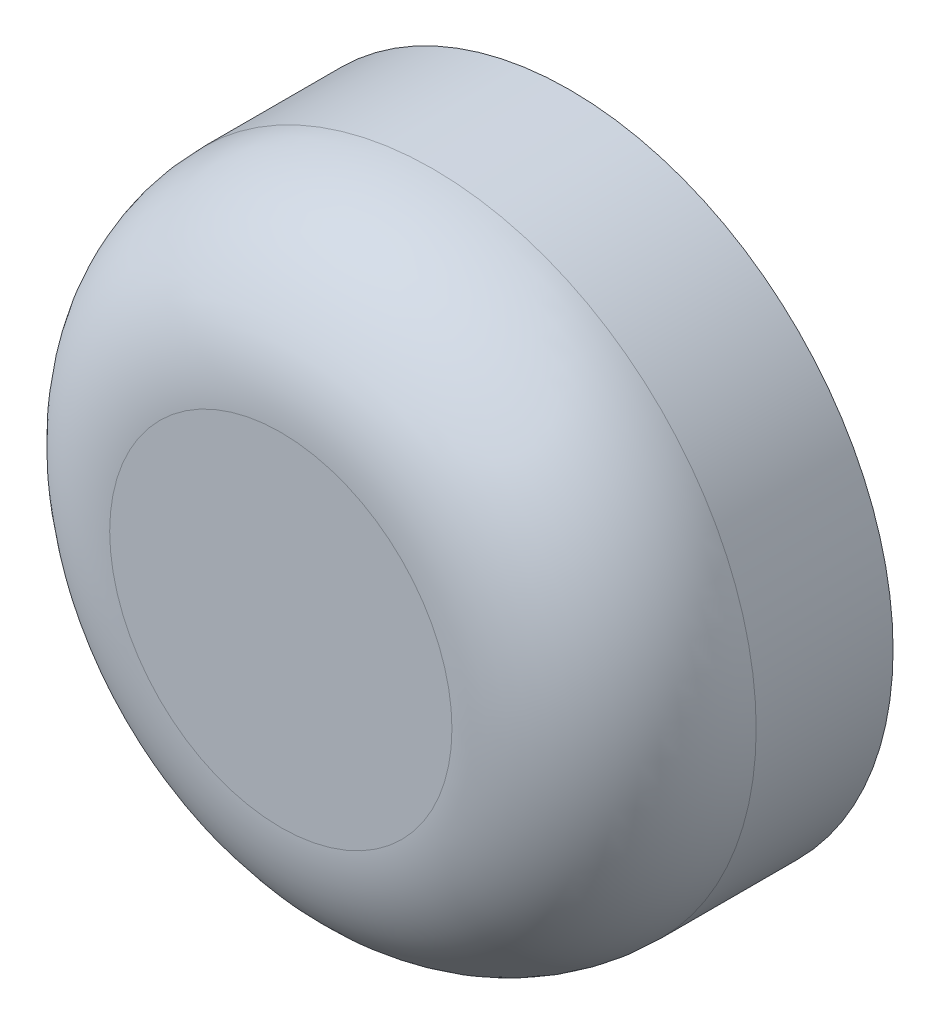
from build123d import *

# Parameters (mm, degrees)
SCHIZZO1_R                   = 4.25
SCHIZZO1_R_2                 = 2.75
ESTRUSIONE_ESTRUSIONE1_DEPTH = 2.8
SCHIZZO2_R                   = 4.25
ESTRUSIONE_ESTRUSIONE2_DEPTH = 1
RACCORDO1_R                  = 2


with BuildPart() as part:
    # Schizzo1 → Estrusione-Estrusione1 (new body)
    with BuildSketch(Plane.XY):
        Circle(SCHIZZO1_R)
        Circle(SCHIZZO1_R_2, mode=Mode.SUBTRACT)
    extrude(amount=ESTRUSIONE_ESTRUSIONE1_DEPTH)

    # Schizzo2 → Estrusione-Estrusione2 (add)
    with BuildSketch(Plane.XY.offset(2.8)):
        Circle(SCHIZZO2_R)
    extrude(amount=ESTRUSIONE_ESTRUSIONE2_DEPTH)

    # Raccordo1
    raccordo1_edges = [part.edges().sort_by_distance(p)[0] for p in [
        (-4.25, 0, 3.8),
    ]]
    fillet(raccordo1_edges, radius=RACCORDO1_R)


solid = part.part
